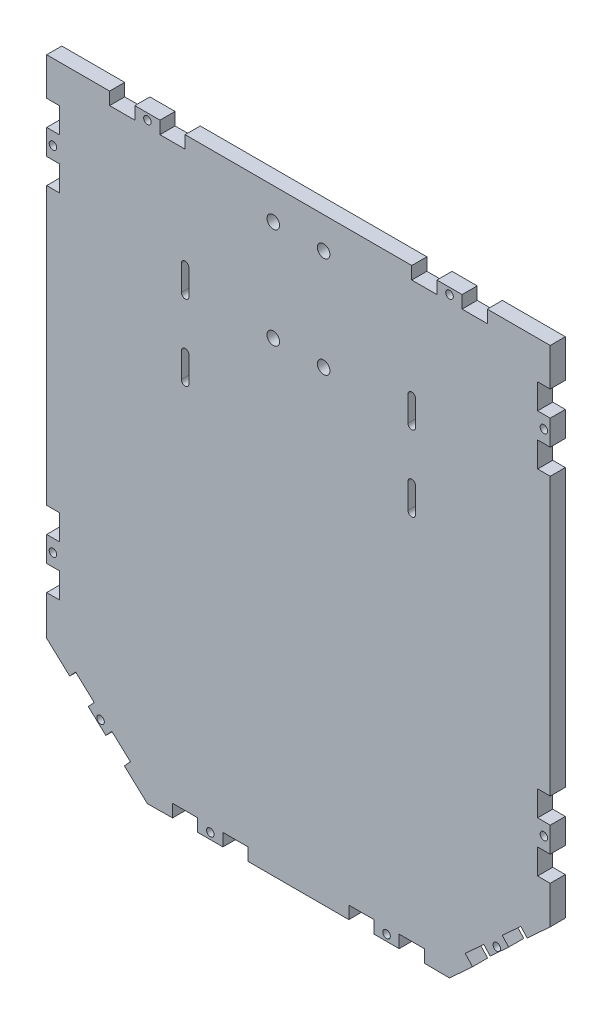
from build123d import *

# Parameters (mm, degrees)
MODEL_R                  = 1.5
MODEL_R_2                = 2.5
RESSALTO_EXTRUS_O1_DEPTH = 6


with BuildPart() as part:
    # Model → Ressalto-extrusão1 (new body)
    with BuildSketch(Plane.XY):
        Polygon((-5, -175), (0, -175), (0, -165), (-5, -165), (-5, -155), (0, -155), (0, -45), (-5, -45), (-5, -35), (0, -35), (0, -25), (-5, -25), (-5, -15), (0, -15), (0, 0), (-25, 0), (-25, -5), (-35, -5), (-35, 0), (-45, 0), (-45, -5), (-55, -5), (-55, 0), (-145, 0), (-145, -5), (-155, -5), (-155, 0), (-165, 0), (-165, -5), (-175, -5), (-175, 0), (-200, 0), (-200, -15), (-195, -15), (-195, -25), (-200, -25), (-200, -35), (-195, -35), (-195, -45), (-200, -45), (-200, -155), (-195, -155), (-195, -165), (-200, -165), (-200, -175), (-195, -175), (-195, -185), (-200, -185), (-200, -200.74174754), (-190.853525683, -209.17356867), (-188.481322389, -206.600305295), (-181.128851073, -213.378296557), (-183.501054367, -215.951559933), (-176.501501675, -222.404207614), (-174.096972592, -219.795878624), (-166.741593597, -226.576550376), (-169.14612268, -229.184879366), (-159.999648363, -237.616700496), (-150, -237.53283976), (-150, -232.5), (-140, -232.5), (-140, -237.5), (-130, -237.5), (-130, -232.5), (-120, -232.5), (-120, -237.5), (-80, -237.5), (-80, -232.5), (-70, -232.5), (-70, -237.5), (-60, -237.5), (-60, -232.5), (-50, -232.5), (-50, -237.5), (-40.000351637, -237.583860737), (-30.85387732, -229.152039608), (-33.759891511, -225.999721294), (-26.407420195, -219.221730032), (-23.852117489, -221.993611718), (-16.496373021, -215.21260305), (-19.051675727, -212.440721364), (-11.69920441, -205.662730102), (-9.146474317, -208.43182113), (0, -200), (0, -185), (-5, -185), align=None)
        with Locations((-2.5, -170)):
            Circle(MODEL_R, mode=Mode.SUBTRACT)
        with Locations((-2.5, -30)):
            Circle(MODEL_R, mode=Mode.SUBTRACT)
        with Locations((-40, -2.5)):
            Circle(MODEL_R, mode=Mode.SUBTRACT)
        with Locations((-160, -2.5)):
            Circle(MODEL_R, mode=Mode.SUBTRACT)
        with Locations((-197.5, -30)):
            Circle(MODEL_R, mode=Mode.SUBTRACT)
        with Locations((-197.5, -170)):
            Circle(MODEL_R, mode=Mode.SUBTRACT)
        with Locations((-65, -235)):
            Circle(MODEL_R, mode=Mode.SUBTRACT)
        with Locations((-135, -235)):
            Circle(MODEL_R, mode=Mode.SUBTRACT)
        with Locations((-90, -52.5)):
            Circle(MODEL_R_2, mode=Mode.SUBTRACT)
        with Locations((-110, -12.5)):
            Circle(MODEL_R_2, mode=Mode.SUBTRACT)
        with Locations((-90, -12.5)):
            Circle(MODEL_R_2, mode=Mode.SUBTRACT)
        with Locations((-110, -52.5)):
            Circle(MODEL_R_2, mode=Mode.SUBTRACT)
        with Locations((-178.608483127, -218.05063468)):
            Circle(MODEL_R, mode=Mode.SUBTRACT)
        with Locations((-21.21191866, -217.474200234)):
            Circle(MODEL_R, mode=Mode.SUBTRACT)
        with BuildLine():
            Line((-56.5, -55), (-56.5, -45))
            ThreePointArc((-56.5, -45), (-55, -43.5), (-53.5, -45))
            Line((-53.5, -45), (-53.5, -55))
            ThreePointArc((-53.5, -55), (-55, -56.5), (-56.5, -55))
        make_face(mode=Mode.SUBTRACT)
        with BuildLine():
            Line((-53.5, -75), (-53.5, -85))
            ThreePointArc((-53.5, -85), (-55, -86.5), (-56.5, -85))
            Line((-56.5, -85), (-56.5, -75))
            ThreePointArc((-56.5, -75), (-55, -73.5), (-53.5, -75))
        make_face(mode=Mode.SUBTRACT)
        with BuildLine():
            Line((-146.5, -85), (-146.5, -75))
            ThreePointArc((-146.5, -75), (-145, -73.5), (-143.5, -75))
            Line((-143.5, -75), (-143.5, -85))
            ThreePointArc((-143.5, -85), (-145, -86.5), (-146.5, -85))
        make_face(mode=Mode.SUBTRACT)
        with BuildLine():
            Line((-146.5, -55), (-146.5, -45))
            ThreePointArc((-146.5, -45), (-145, -43.5), (-143.5, -45))
            Line((-143.5, -45), (-143.5, -55))
            ThreePointArc((-143.5, -55), (-145, -56.5), (-146.5, -55))
        make_face(mode=Mode.SUBTRACT)
    extrude(amount=RESSALTO_EXTRUS_O1_DEPTH)


solid = part.part
